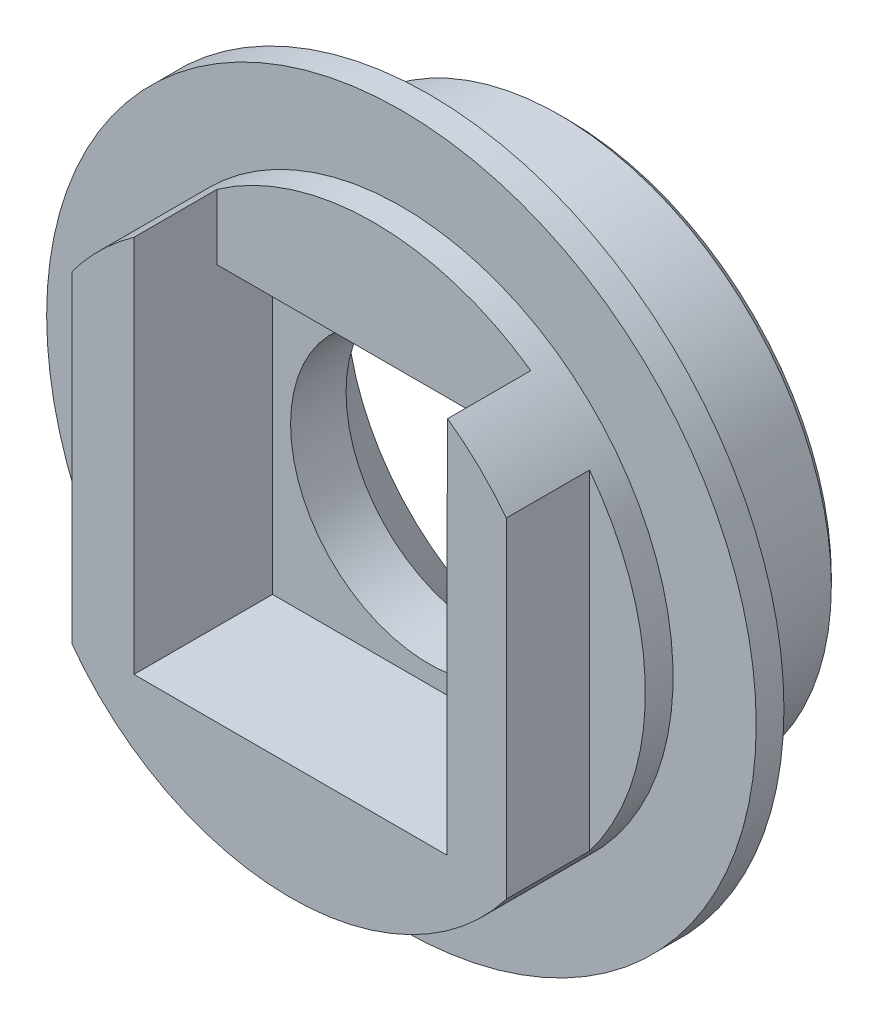
from build123d import *

# Parameters (mm, degrees)
SKETCH1_R           = 9.8
SKETCH1_R_2         = 5
BOSS_EXTRUDE1_DEPTH = 10
SKETCH2_W           = 11.3
SKETCH2_H           = 11.3
CUT_EXTRUDE1_DEPTH  = 5
SKETCH3_W           = 11.313408722
SKETCH3_H           = 4.707055676
CUT_EXTRUDE2_DEPTH  = 3
SKETCH4_W           = 5.404805584
SKETCH4_H           = 18.076359344
SKETCH4_W_2         = 5.663408722
SKETCH4_H_2         = 17.947057775
CUT_EXTRUDE3_DEPTH  = 3
CHAMFER1_SIZE       = 3
CHAMFER2_SIZE       = 0.29
SKETCH5_R           = 12.8
SKETCH5_R_2         = 9.8
BOSS_EXTRUDE2_DEPTH = 1


with BuildPart() as part:
    # Sketch1 → Boss-Extrude1 (new body)
    with BuildSketch(Plane.XY):
        Circle(SKETCH1_R)
        Circle(SKETCH1_R_2, mode=Mode.SUBTRACT)
    extrude(amount=BOSS_EXTRUDE1_DEPTH)

    # Sketch2 → Cut-Extrude1 (cut)
    with BuildSketch(Plane.XY.offset(10)):
        Rectangle(SKETCH2_W, SKETCH2_H)
    extrude(amount=-CUT_EXTRUDE1_DEPTH, mode=Mode.SUBTRACT)

    # Sketch3 → Cut-Extrude2 (cut)
    with BuildSketch(Plane.XY.offset(10)):
        with Locations((0.006704361, 8.003527838)):
            Rectangle(SKETCH3_W, SKETCH3_H)
    extrude(amount=-CUT_EXTRUDE2_DEPTH, mode=Mode.SUBTRACT)

    # Sketch4 → Cut-Extrude3 (cut)
    with BuildSketch(Plane.XY.offset(10)):
        with Locations((-10.5897985, 0)):
            Rectangle(SKETCH4_W, SKETCH4_H)
        with Locations((10.615658814, 0.064650784)):
            Rectangle(SKETCH4_W_2, SKETCH4_H_2)
    extrude(amount=-CUT_EXTRUDE3_DEPTH, mode=Mode.SUBTRACT)

    # Chamfer1
    chamfer1_edges = [part.edges().sort_by_distance(p)[0] for p in [
        (-5, 0, 0),
    ]]
    chamfer(chamfer1_edges, length=CHAMFER1_SIZE)

    # Chamfer2
    chamfer2_edges = [part.edges().sort_by_distance(p)[0] for p in [
        (-9.8, 0, 0),
    ]]
    chamfer(chamfer2_edges, length=CHAMFER2_SIZE)

    # Sketch5 → Boss-Extrude2 (add)
    with BuildSketch(Plane(origin=(0, 0, 5), x_dir=(-1, 0, 0), z_dir=(0, 0, -1))):
        Circle(SKETCH5_R)
        Circle(SKETCH5_R_2, mode=Mode.SUBTRACT)
    extrude(amount=-BOSS_EXTRUDE2_DEPTH)


solid = part.part
